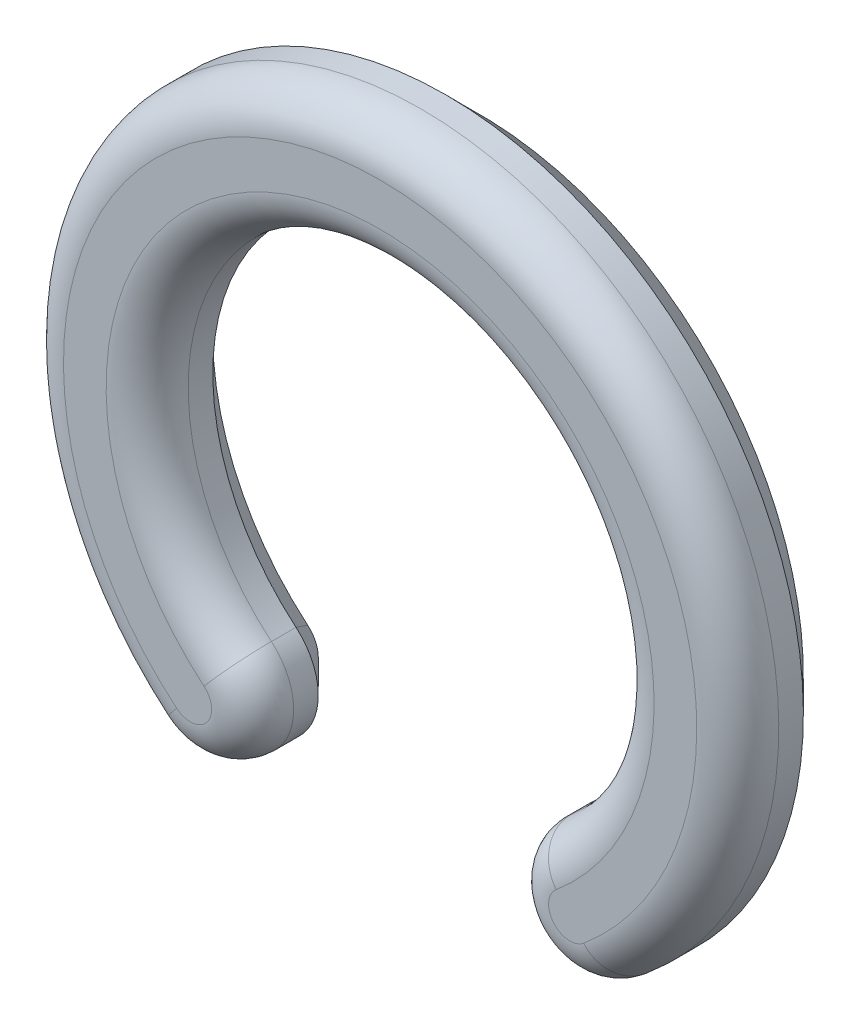
from build123d import *

# Parameters (mm, degrees)
BOSS_EXTRUDE1_DEPTH = 3
CHAMFER1_SIZE       = 1
FILLET1_R           = 1.25


with BuildPart() as part:
    # Sketch1 → Boss-Extrude1 (new body)
    with BuildSketch(Plane.XY):
        with BuildLine():
            ThreePointArc((4.563792029, -5.438915546), (0, 7.1), (-4.563792029, -5.438915546))
            ThreePointArc((-4.563792029, -5.438915546), (-4.329604045, -8.115696446), (-7.006384946, -8.34988443))
            ThreePointArc((-7.006384946, -8.34988443), (0, 10.9), (7.006384946, -8.34988443))
            ThreePointArc((7.006384946, -8.34988443), (4.329604045, -8.115696446), (4.563792029, -5.438915546))
        make_face()
    extrude(amount=BOSS_EXTRUDE1_DEPTH)

    # Chamfer1
    chamfer1_edges = [part.edges().sort_by_distance(p)[0] for p in [
        (0, 10.9, 0),
        (4.329604045, -8.115696446, 0),
        (0, 7.1, 0),
        (-4.329604045, -8.115696446, 0),
    ]]
    chamfer(chamfer1_edges, length=CHAMFER1_SIZE)

    # Fillet1
    fillet1_edges = [part.edges().sort_by_distance(p)[0] for p in [
        (4.329604045, -8.115696446, 3),
        (0, 10.9, 3),
        (-4.329604045, -8.115696446, 3),
        (0, 7.1, 3),
    ]]
    fillet(fillet1_edges, radius=FILLET1_R)


solid = part.part
